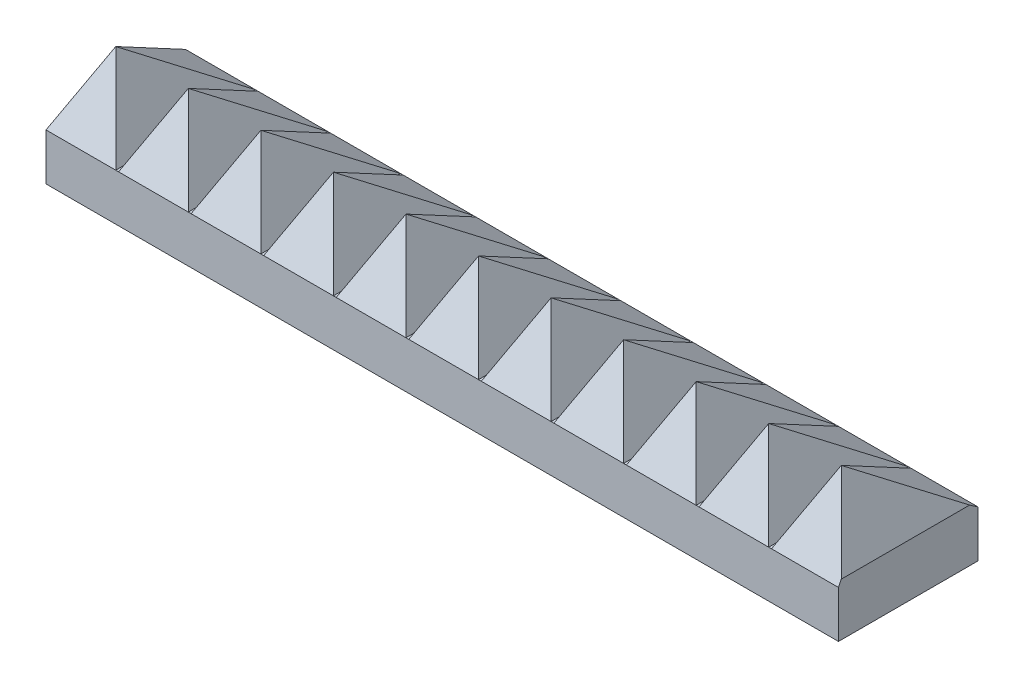
from build123d import *

# Parameters (mm, degrees)
SKETCH1_W           = 19.05
SKETCH1_H           = 19.05
BOSS_EXTRUDE2_DEPTH = 6.35
SKETCH8_W           = 217.17
SKETCH8_H           = 38.1
BOSS_EXTRUDE4_DEPTH = 6.35
SKETCH8_5_W         = 217.17
SKETCH8_5_H         = 38.1
BOSS_EXTRUDE5_DEPTH = 6.4262
LPATTERN3_COUNT     = 11
LPATTERN3_PITCH     = 19.812
SKETCH15_R          = 12.192
BOSS_EXTRUDE6_DEPTH = 6.35
SKETCH16_W          = 38.1
SKETCH16_H          = 22.073264639
CUT_EXTRUDE1_DEPTH  = 3.302


with BuildPart() as part:
    # Sketch1 → Boss-Extrude2 (new body)
    with BuildSketch(Plane(origin=(0, 0, 0), x_dir=(1, 0, 0), z_dir=(0, 1, 0))):
        with Locations((9.525, -9.525)):
            Rectangle(SKETCH1_W, SKETCH1_H)
    extrude(amount=BOSS_EXTRUDE2_DEPTH)

    # Sketch8 → Boss-Extrude4 (add)
    with BuildSketch(Plane(origin=(0, 0, 0), x_dir=(1, 0, 0), z_dir=(0, 1, 0))):
        with Locations((108.585, -9.525)):
            Rectangle(SKETCH8_W, SKETCH8_H)
    extrude(amount=BOSS_EXTRUDE4_DEPTH)

    # Sketch8_5 → Boss-Extrude5 (add)
    with BuildSketch(Plane(origin=(0, 0, 0), x_dir=(1, 0, 0), z_dir=(0, 1, 0))):
        with Locations((108.585, -9.525)):
            Rectangle(SKETCH8_5_W, SKETCH8_5_H)
    extrude(amount=-BOSS_EXTRUDE5_DEPTH)

    # Sketch9 → Loft3 section 0
    with BuildSketch(Plane(origin=(0, 6.35, 0), x_dir=(1, 0, 0), z_dir=(0, 1, 0)), mode=Mode.PRIVATE) as loft3_s0:
        with BuildLine():
            Line((0, 9.525), (19.05, 9.525))
            Line((19.05, 9.525), (19.05, -28.575))
            Line((19.05, -28.575), (0, -28.575))
            Line((0, -28.575), (0, 9.525))
        make_face()
    loft3 = loft([loft3_s0.sketch, Vertex(9.525, 26.0731, 19.05)])

    # LPattern3: Loft3 ×11
    with Locations(*[(i * LPATTERN3_PITCH, 0, 0) for i in range(1, LPATTERN3_COUNT)]):
        add(loft3)

    # Sketch15 → Boss-Extrude6 (add)
    with BuildSketch(Plane.XZ.offset(6.4262)):
        with Locations((179.07, 9.525)):
            Circle(SKETCH15_R)
        with Locations((38.1, 9.525)):
            Circle(SKETCH15_R)
        with Locations((108.585, 9.525)):
            Circle(SKETCH15_R)
    extrude(amount=BOSS_EXTRUDE6_DEPTH)

    # Sketch16 → Cut-Extrude1 (cut)
    with BuildSketch(Plane(origin=(219.71, 0, 0), x_dir=(0, 0, -1), z_dir=(1, 0, 0))):
        with Locations((-9.525, 4.61043232)):
            Rectangle(SKETCH16_W, SKETCH16_H)
    extrude(amount=-CUT_EXTRUDE1_DEPTH, mode=Mode.SUBTRACT)


solid = part.part
